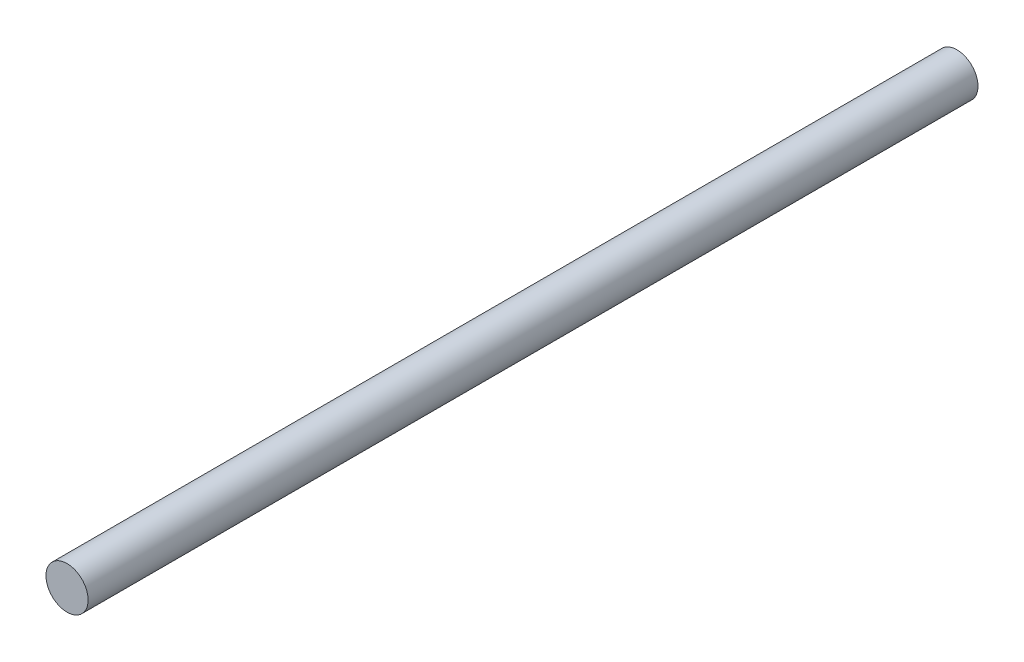
from build123d import *

# Parameters (mm, degrees)
SKETCH1_R           = 11.43
BOSS_EXTRUDE1_DEPTH = 482.6


with BuildPart() as part:
    # Sketch1 → Boss-Extrude1 (new body)
    with BuildSketch(Plane.XY):
        Circle(SKETCH1_R)
    extrude(amount=BOSS_EXTRUDE1_DEPTH)


solid = part.part
